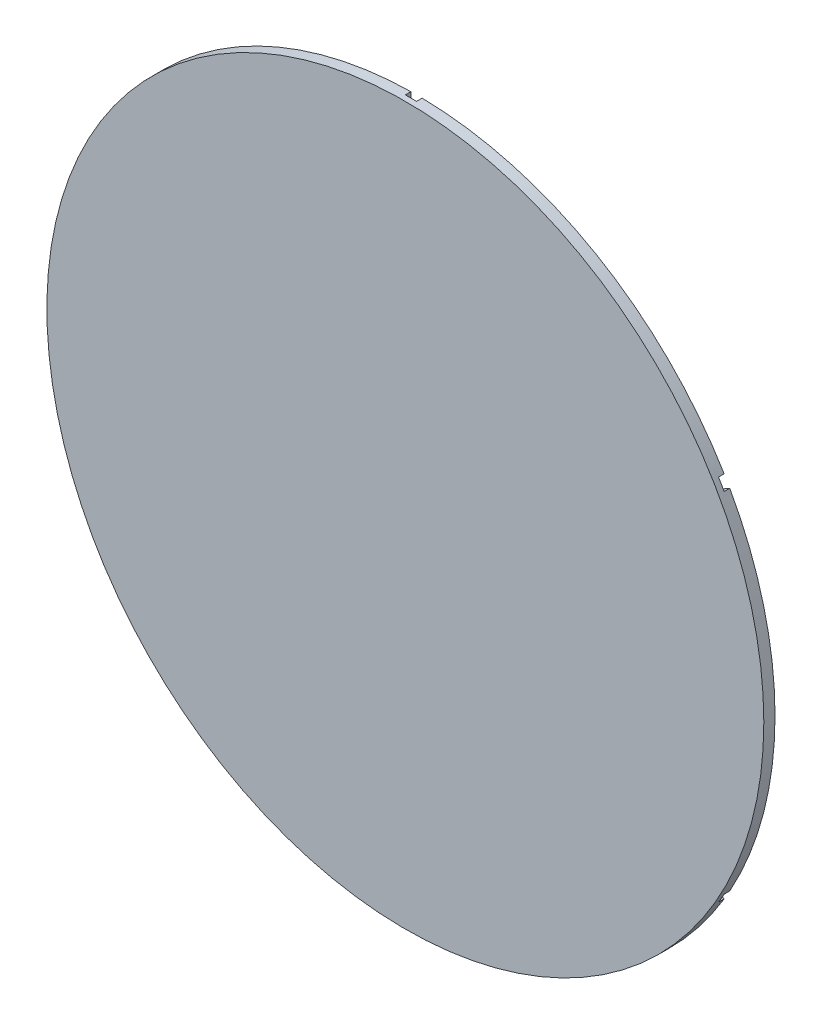
from build123d import *

# Parameters (mm, degrees)
SKETCH1_R           = 101.6
BOSS_EXTRUDE1_DEPTH = 3.175
CUT_EXTRUDE3_DEPTH  = 1.5875


with BuildPart() as part:
    # Sketch1 → Boss-Extrude1 (new body)
    with BuildSketch(Plane.XY):
        Circle(SKETCH1_R)
    extrude(amount=BOSS_EXTRUDE1_DEPTH)

    # Sketch2 → Cut-Extrude3 (cut)
    with BuildSketch(Plane(origin=(0, 0, 0), x_dir=(-1, 0, 0), z_dir=(0, 0, -1))):
        with BuildLine():
            ThreePointArc((-88.771189624, -49.418983121), (-87.988181024, -50.8), (-87.183689624, -52.168613778))
            Line((-87.183689624, -52.168613778), (-1.5875, -2.749630657))
            Line((-1.5875, -2.749630657), (-1.5875, -0.916543552))
            Line((-1.5875, -0.916543552), (-3.175, 0))
            Line((-3.175, 0), (-88.771189624, -49.418983121))
        make_face()
        Polygon((-1.5875, -0.916543552), (-1.5875, -2.749630657), (0, -1.833087105), align=None)
        Polygon((-1.5875, -0.916543552), (0, -1.833087105), (1.5875, -0.916543552), (1.5875, 0.916543552), (0, 1.833087105), (-1.5875, 0.916543552), align=None)
        Polygon((1.5875, -0.916543552), (0, -1.833087105), (1.5875, -2.749630657), align=None)
        Polygon((-3.175, 0), (-1.5875, -0.916543552), (-1.5875, 0.916543552), align=None)
        Polygon((-1.5875, 2.749630657), (-1.5875, 0.916543552), (0, 1.833087105), align=None)
        Polygon((0, 1.833087105), (1.5875, 0.916543552), (1.5875, 2.749630657), align=None)
        Polygon((1.5875, 0.916543552), (1.5875, -0.916543552), (3.175, 0), align=None)
        with BuildLine():
            Line((1.5875, 0.916543552), (3.175, 0))
            Line((3.175, 0), (88.771189624, 49.418983121))
            ThreePointArc((88.771189624, 49.418983121), (87.988181024, 50.8), (87.183689624, 52.168613778))
            Line((87.183689624, 52.168613778), (1.5875, 2.749630657))
            Line((1.5875, 2.749630657), (1.5875, 0.916543552))
        make_face()
        with BuildLine():
            Line((3.175, 0), (1.5875, -0.916543552))
            Line((1.5875, -0.916543552), (1.5875, -2.749630657))
            Line((1.5875, -2.749630657), (87.183689624, -52.168613778))
            ThreePointArc((87.183689624, -52.168613778), (87.988181024, -50.8), (88.771189624, -49.418983121))
            Line((88.771189624, -49.418983121), (3.175, 0))
        make_face()
        with BuildLine():
            Line((-1.5875, 2.749630657), (0, 1.833087105))
            Line((0, 1.833087105), (1.5875, 2.749630657))
            Line((1.5875, 2.749630657), (1.5875, 101.587596899))
            ThreePointArc((1.5875, 101.587596899), (0, 101.6), (-1.5875, 101.587596899))
            Line((-1.5875, 101.587596899), (-1.5875, 2.749630657))
        make_face()
        with BuildLine():
            Line((-88.771189624, 49.418983121), (-3.175, 0))
            Line((-3.175, 0), (-1.5875, 0.916543552))
            Line((-1.5875, 0.916543552), (-1.5875, 2.749630657))
            Line((-1.5875, 2.749630657), (-87.183689624, 52.168613778))
            ThreePointArc((-87.183689624, 52.168613778), (-87.988181024, 50.8), (-88.771189624, 49.418983121))
        make_face()
        with BuildLine():
            Line((0, -1.833087105), (-1.5875, -2.749630657))
            Line((-1.5875, -2.749630657), (-1.5875, -101.587596899))
            ThreePointArc((-1.5875, -101.587596899), (0, -101.6), (1.5875, -101.587596899))
            Line((1.5875, -101.587596899), (1.5875, -2.749630657))
            Line((1.5875, -2.749630657), (0, -1.833087105))
        make_face()
    extrude(amount=-CUT_EXTRUDE3_DEPTH, mode=Mode.SUBTRACT)


solid = part.part
